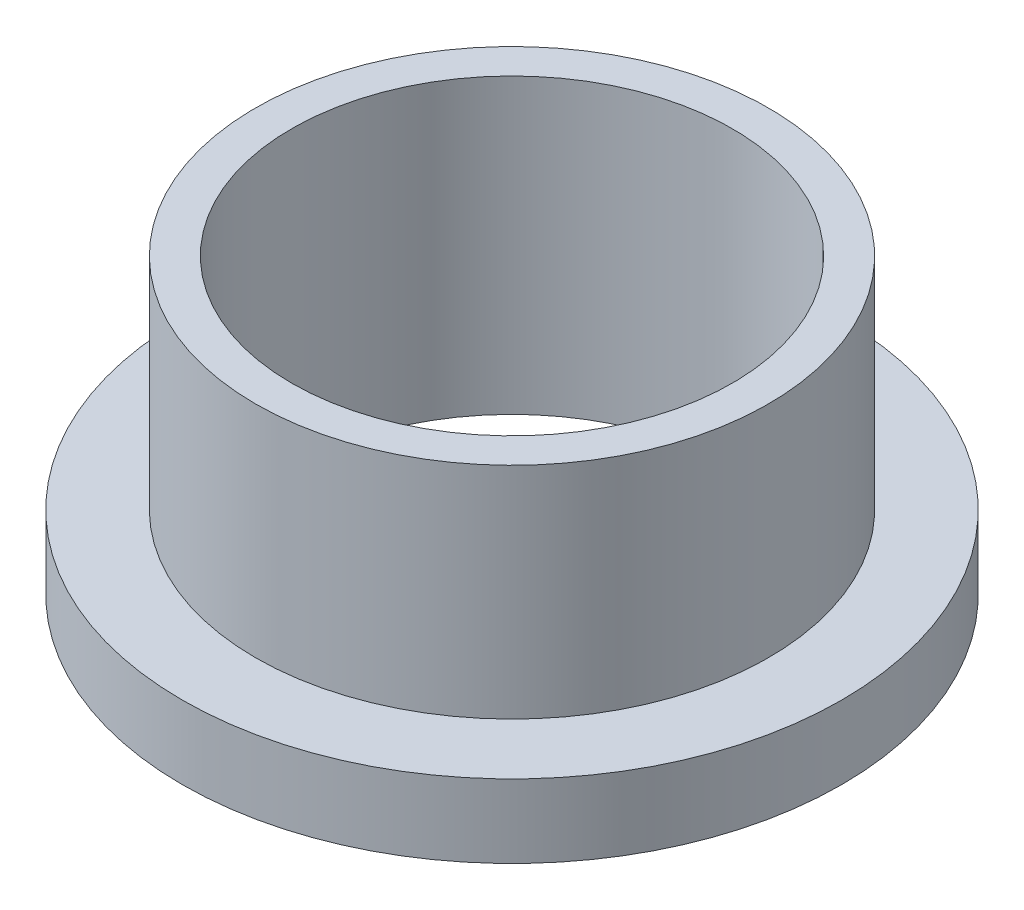
from build123d import *

# Parameters (mm, degrees)
SKETCH2_R           = 11.1125
SKETCH2_R_2         = 9.5504
BOSS_EXTRUDE1_DEPTH = 12.7
SKETCH3_R           = 14.2875
SKETCH3_R_2         = 11.1125
BOSS_EXTRUDE2_DEPTH = 3.175


with BuildPart() as part:
    # Sketch2 → Boss-Extrude1 (new body)
    with BuildSketch(Plane(origin=(0, 0, 0), x_dir=(1, 0, 0), z_dir=(0, 1, 0))):
        Circle(SKETCH2_R)
        Circle(SKETCH2_R_2, mode=Mode.SUBTRACT)
    extrude(amount=BOSS_EXTRUDE1_DEPTH)

    # Sketch3 → Boss-Extrude2 (add)
    with BuildSketch(Plane(origin=(0, 0, 0), x_dir=(1, 0, 0), z_dir=(0, 1, 0))):
        Circle(SKETCH3_R)
        Circle(SKETCH3_R_2, mode=Mode.SUBTRACT)
    extrude(amount=BOSS_EXTRUDE2_DEPTH)


solid = part.part
